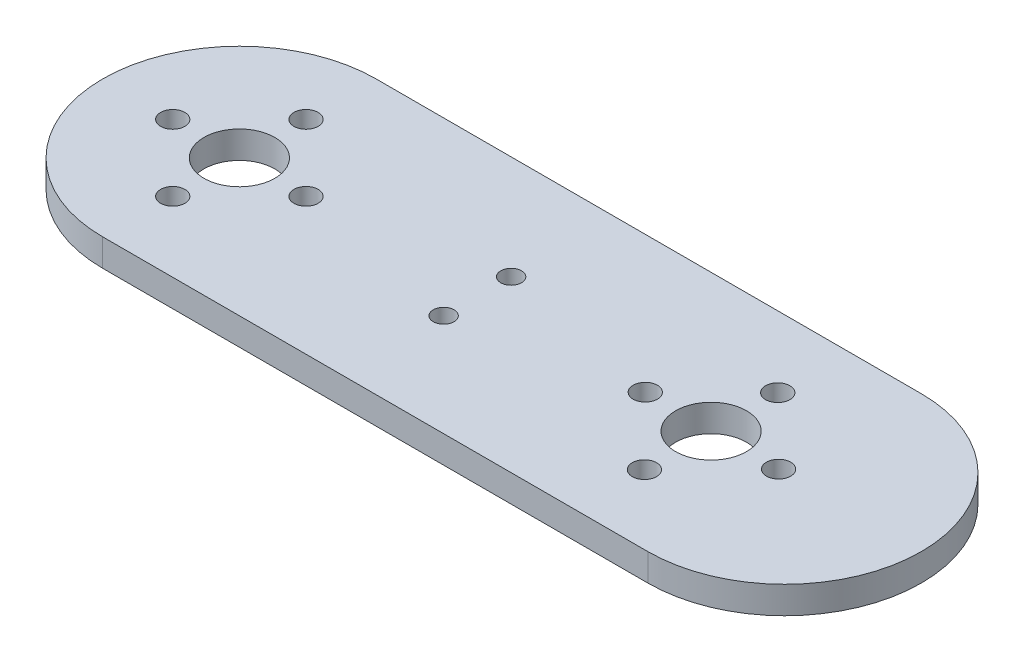
from build123d import *

# Parameters (mm, degrees)
SKETCH1_R               = 0.5
SKETCH1_R_2             = 1.375
BOSS_EXTRUDE1_DEPTH     = 2
SKETCH4_R               = 4.6270037
SKETCH4_R_2             = 2.6270037
BOSS_EXTRUDE3_DEPTH     = 2.5
CUT_EXTRUDE3_DEPTH      = 2.5
SKETCH6_R               = 20.066
SKETCH6_R_2             = 3.75
BOSS_EXTRUDE6_DEPTH     = 2.54
SKETCH7_R               = 1.778
CUT_EXTRUDE4_DEPTH      = 2.54
CIRPATTERN1_COUNT       = 4
BOSS_EXTRU_1_DEPTH      = 2.2225
BOSS_EXTRU_1_DEPTH_BACK = 2.54
ESQUISSE3_R             = 20.066
ESQUISSE3_R_2           = 1.778
ESQUISSE3_R_3           = 1.375
BOSS_EXTRU_2_DEPTH      = 2.2225
ENL_V_MAT_EXTRU_1_REACH = 104.179
ESQUISSE4_W             = 40.894
ESQUISSE4_H             = 20.066
ESQUISSE5_R             = 1.524
ENL_V_MAT_EXTRU_2_DEPTH = 103.178919246
ESQUISSE6_W             = 129.807809177
ESQUISSE6_H             = 84.506546368
ENL_V_MAT_EXTRU_3_DEPTH = 0.76
ESQUISSE7_R             = 5.2
ENL_V_MAT_EXTRU_4_DEPTH = 103.241877615
ESQUISSE8_W             = 40.894
ESQUISSE8_H             = 20.066
BOSS_EXTRU_3_DEPTH      = 4.0025
ESQUISSE9_R             = 5.2
ENL_V_MAT_EXTRU_5_DEPTH = 10
ESQUISSE11_R            = 1.78
ENL_V_MAT_EXTRU_6_DEPTH = 10
ESQUISSE10_R            = 1.524
BOSS_EXTRU_4_DEPTH      = 4.0025


with BuildPart() as part:
    # Sketch1 → Boss-Extrude1 (new body)
    with BuildSketch(Plane(origin=(0, 0, 0), x_dir=(1, 0, 0), z_dir=(0, 1, 0))):
        with BuildLine():
            Line((-4, 4), (-2.467435953, 13.402193757))
            ThreePointArc((-2.467435953, 13.402193757), (0, 15.5), (2.467435953, 13.402193757))
            Line((2.467435953, 13.402193757), (4, 4))
            Line((4, 4), (12.448472752, 2.459445505))
            ThreePointArc((12.448472752, 2.459445505), (14.5, 0), (12.448472752, -2.459445505))
            Line((12.448472752, -2.459445505), (4, -4))
            Line((4, -4), (2.467435953, -13.402193757))
            ThreePointArc((2.467435953, -13.402193757), (0, -15.5), (-2.467435953, -13.402193757))
            Line((-2.467435953, -13.402193757), (-4, -4))
            Line((-4, -4), (-12.448472752, -2.459445505))
            ThreePointArc((-12.448472752, -2.459445505), (-14.5, 0), (-12.448472752, 2.459445505))
            Line((-12.448472752, 2.459445505), (-4, 4))
        make_face()
        with Locations(Location((0, 12, 0), (0, 0, 270))):
            Circle(SKETCH1_R, mode=Mode.SUBTRACT)
        with Locations(Location((0, 9.5, 0), (0, 0, 270))):
            Circle(SKETCH1_R, mode=Mode.SUBTRACT)
        with Locations(Location((0, 7.5, 0), (0, 0, 270))):
            Circle(SKETCH1_R, mode=Mode.SUBTRACT)
        with Locations(Location((12, 0, 0), (0, 0, 270))):
            Circle(SKETCH1_R, mode=Mode.SUBTRACT)
        with Locations(Location((9.5, 0, 0), (0, 0, 270))):
            Circle(SKETCH1_R, mode=Mode.SUBTRACT)
        with Locations(Location((7.5, 0, 0), (0, 0, 270))):
            Circle(SKETCH1_R, mode=Mode.SUBTRACT)
        with Locations(Location((0, -12, 0), (0, 0, 270))):
            Circle(SKETCH1_R, mode=Mode.SUBTRACT)
        with Locations(Location((0, -9.5, 0), (0, 0, 270))):
            Circle(SKETCH1_R, mode=Mode.SUBTRACT)
        with Locations(Location((0, -7.5, 0), (0, 0, 270))):
            Circle(SKETCH1_R, mode=Mode.SUBTRACT)
        with Locations(Location((-12, 0, 0), (0, 0, 270))):
            Circle(SKETCH1_R, mode=Mode.SUBTRACT)
        with Locations(Location((-9.5, 0, 0), (0, 0, 270))):
            Circle(SKETCH1_R, mode=Mode.SUBTRACT)
        with Locations(Location((-7.5, 0, 0), (0, 0, 270))):
            Circle(SKETCH1_R, mode=Mode.SUBTRACT)
        with Locations(Location((0, 0, 0), (0, 0, 270))):
            Circle(SKETCH1_R_2, mode=Mode.SUBTRACT)
    extrude(amount=BOSS_EXTRUDE1_DEPTH)

    # Sketch4 → Boss-Extrude3 (add)
    with BuildSketch(Plane.XZ):
        with Locations(Location((0, 0, 0), (0, 0, 90))):
            Circle(SKETCH4_R)
        with Locations(Location((0, 0, 0), (0, 0, 270))):
            Circle(SKETCH4_R_2, mode=Mode.SUBTRACT)
    extrude(amount=BOSS_EXTRUDE3_DEPTH)

    # Sketch5 → Cut-Extrude3 (cut)
    with BuildSketch(Plane.XZ.offset(2.5)):
        with BuildLine():
            Line((0.282820055, 2.611735296), (0, 3.101594))
            Line((0, 3.101594), (-0.282820055, 2.611735296))
            ThreePointArc((-0.282820055, 2.611735296), (-0.410953918, 2.594660925), (-0.538092735, 2.571304075))
            Line((-0.538092735, 2.571304075), (-0.958445256, 2.949791185))
            Line((-0.958445256, 2.949791185), (-1.076048447, 2.396511669))
            ThreePointArc((-1.076048447, 2.396511669), (-1.192634723, 2.340677436), (-1.306333259, 2.279175696))
            Line((-1.306333259, 2.279175696), (-1.823071212, 2.509242256))
            Line((-1.823071212, 2.509242256), (-1.76394572, 1.946700782))
            ThreePointArc((-1.76394572, 1.946700782), (-1.85757213, 1.85757213), (-1.946700782, 1.76394572))
            Line((-1.946700782, 1.76394572), (-2.509242256, 1.823071212))
            Line((-2.509242256, 1.823071212), (-2.279175696, 1.306333259))
            ThreePointArc((-2.279175696, 1.306333259), (-2.340677436, 1.192634723), (-2.396511669, 1.076048447))
            Line((-2.396511669, 1.076048447), (-2.949791185, 0.958445256))
            Line((-2.949791185, 0.958445256), (-2.571304075, 0.538092735))
            ThreePointArc((-2.571304075, 0.538092735), (-2.594660925, 0.410953918), (-2.611735296, 0.282820055))
            Line((-2.611735296, 0.282820055), (-3.101594, 0))
            Line((-3.101594, 0), (-2.611735296, -0.282820055))
            ThreePointArc((-2.611735296, -0.282820055), (-2.594660925, -0.410953918), (-2.571304075, -0.538092735))
            Line((-2.571304075, -0.538092735), (-2.949791185, -0.958445256))
            Line((-2.949791185, -0.958445256), (-2.396511669, -1.076048447))
            ThreePointArc((-2.396511669, -1.076048447), (-2.340677436, -1.192634723), (-2.279175696, -1.306333259))
            Line((-2.279175696, -1.306333259), (-2.509242256, -1.823071212))
            Line((-2.509242256, -1.823071212), (-1.946700782, -1.76394572))
            ThreePointArc((-1.946700782, -1.76394572), (-1.85757213, -1.85757213), (-1.76394572, -1.946700782))
            Line((-1.76394572, -1.946700782), (-1.823071212, -2.509242256))
            Line((-1.823071212, -2.509242256), (-1.306333259, -2.279175696))
            ThreePointArc((-1.306333259, -2.279175696), (-1.192634723, -2.340677436), (-1.076048447, -2.396511669))
            Line((-1.076048447, -2.396511669), (-0.958445256, -2.949791185))
            Line((-0.958445256, -2.949791185), (-0.538092735, -2.571304075))
            ThreePointArc((-0.538092735, -2.571304075), (-0.410953918, -2.594660925), (-0.282820055, -2.611735296))
            Line((-0.282820055, -2.611735296), (0, -3.101594))
            Line((0, -3.101594), (0.282820055, -2.611735296))
            ThreePointArc((0.282820055, -2.611735296), (0.410953918, -2.594660925), (0.538092735, -2.571304075))
            Line((0.538092735, -2.571304075), (0.958445256, -2.949791185))
            Line((0.958445256, -2.949791185), (1.076048447, -2.396511669))
            ThreePointArc((1.076048447, -2.396511669), (1.192634723, -2.340677436), (1.306333259, -2.279175696))
            Line((1.306333259, -2.279175696), (1.823071212, -2.509242256))
            Line((1.823071212, -2.509242256), (1.76394572, -1.946700782))
            ThreePointArc((1.76394572, -1.946700782), (1.85757213, -1.85757213), (1.946700782, -1.76394572))
            Line((1.946700782, -1.76394572), (2.509242256, -1.823071212))
            Line((2.509242256, -1.823071212), (2.279175696, -1.306333259))
            ThreePointArc((2.279175696, -1.306333259), (2.340677436, -1.192634723), (2.396511669, -1.076048447))
            Line((2.396511669, -1.076048447), (2.949791185, -0.958445256))
            Line((2.949791185, -0.958445256), (2.571304075, -0.538092735))
            ThreePointArc((2.571304075, -0.538092735), (2.594660925, -0.410953918), (2.611735296, -0.282820055))
            Line((2.611735296, -0.282820055), (3.101594, 0))
            Line((3.101594, 0), (2.611735296, 0.282820055))
            ThreePointArc((2.611735296, 0.282820055), (2.594660925, 0.410953918), (2.571304075, 0.538092735))
            Line((2.571304075, 0.538092735), (2.949791185, 0.958445256))
            Line((2.949791185, 0.958445256), (2.396511669, 1.076048447))
            ThreePointArc((2.396511669, 1.076048447), (2.340677436, 1.192634723), (2.279175696, 1.306333259))
            Line((2.279175696, 1.306333259), (2.509242256, 1.823071212))
            Line((2.509242256, 1.823071212), (1.946700782, 1.76394572))
            ThreePointArc((1.946700782, 1.76394572), (1.85757213, 1.85757213), (1.76394572, 1.946700782))
            Line((1.76394572, 1.946700782), (1.823071212, 2.509242256))
            Line((1.823071212, 2.509242256), (1.306333259, 2.279175696))
            ThreePointArc((1.306333259, 2.279175696), (1.192634723, 2.340677436), (1.076048447, 2.396511669))
            Line((1.076048447, 2.396511669), (0.958445256, 2.949791185))
            Line((0.958445256, 2.949791185), (0.538092735, 2.571304075))
            ThreePointArc((0.538092735, 2.571304075), (0.410953918, 2.594660925), (0.282820055, 2.611735296))
        make_face()
    extrude(amount=-CUT_EXTRUDE3_DEPTH, mode=Mode.SUBTRACT)

    # Sketch6 → Boss-Extrude6 (add)
    with BuildSketch(Plane(origin=(0, 2, 0), x_dir=(1, 0, 0), z_dir=(0, 1, 0))):
        with Locations(Location((0, 0, 0), (0, 0, 270))):
            Circle(SKETCH6_R)
        Circle(SKETCH6_R_2, mode=Mode.SUBTRACT)
    extrude(amount=-BOSS_EXTRUDE6_DEPTH)

    # Sketch7 → Cut-Extrude4 (cut)
    with BuildSketch(Plane(origin=(0, 2, 0), x_dir=(1, 0, 0), z_dir=(0, 1, 0))):
        with Locations(Location((0, 9.779, 0), (0, 0, 270))):
            Circle(SKETCH7_R)
    cut_extrude4 = extrude(amount=-CUT_EXTRUDE4_DEPTH, mode=Mode.SUBTRACT)

    # CirPattern1: Cut-Extrude4 ×4 about axis
    cirpattern1_axis = Axis((0, 0, 0), (0, 1, 0))
    for i in range(1, CIRPATTERN1_COUNT):
        add(cut_extrude4.rotate(cirpattern1_axis, i * 360 / CIRPATTERN1_COUNT), mode=Mode.SUBTRACT)

    # Esquisse1 → Boss.-Extru.1 (add, two sides)
    with BuildSketch(Plane(origin=(0, 2, 0), x_dir=(1, 0, 0), z_dir=(0, 1, 0))) as boss_extru_1_sk:
        with BuildLine():
            Line((0, 20.066), (80.01, 20.066))
            ThreePointArc((80.01, 20.066), (100.076, 0), (80.01, -20.066))
            Line((80.01, -20.066), (0, -20.066))
            ThreePointArc((0, -20.066), (20.066, 0), (0, 20.066))
        make_face()
    extrude(amount=BOSS_EXTRU_1_DEPTH)
    extrude(boss_extru_1_sk.sketch, amount=-BOSS_EXTRU_1_DEPTH_BACK)

    # Esquisse3 → Boss.-Extru.2 (add)
    with BuildSketch(Plane(origin=(0, 2, 0), x_dir=(1, 0, 0), z_dir=(0, 1, 0))):
        Circle(ESQUISSE3_R)
        with Locations(Location((9.779, 0, 0), (0, 0, 270))):
            Circle(ESQUISSE3_R_2, mode=Mode.SUBTRACT)
        with Locations(Location((0, 9.779, 0), (0, 0, 270))):
            Circle(ESQUISSE3_R_2, mode=Mode.SUBTRACT)
        with Locations(Location((-9.779, 0, 0), (0, 0, 270))):
            Circle(ESQUISSE3_R_2, mode=Mode.SUBTRACT)
        with Locations(Location((0, -9.779, 0), (0, 0, 270))):
            Circle(ESQUISSE3_R_2, mode=Mode.SUBTRACT)
        with Locations(Location((0, 0, 0), (0, 0, 270))):
            Circle(ESQUISSE3_R_3, mode=Mode.SUBTRACT)
    extrude(amount=BOSS_EXTRU_2_DEPTH)

    # Esquisse4 → Enlèv. mat.-Extru.1 (cut, up to next)
    with BuildSketch(Plane.XZ.offset(0.54), mode=Mode.PRIVATE) as enl_v_mat_extru_1_sk1:
        with Locations((59.563, 0.127)):
            Rectangle(ESQUISSE4_W, ESQUISSE4_H)
    enl_v_mat_extru_1_tool1 = extrude(enl_v_mat_extru_1_sk1.sketch, amount=-ENL_V_MAT_EXTRU_1_REACH, mode=Mode.PRIVATE) & part.part
    add(enl_v_mat_extru_1_tool1.solids().sort_by_distance((59.563, -0.54, 0.127))[0], mode=Mode.SUBTRACT)

    # Esquisse5 → Enlèv. mat.-Extru.2 (cut, through all)
    with BuildSketch(Plane(origin=(0, -0.54, 0), x_dir=(-1, 0, 0), z_dir=(0, -1, 0))):
        with Locations(Location((-35.052, -5.08, 0), (0, 0, 90))):
            Circle(ESQUISSE5_R)
        with Locations(Location((-35.052, 4.826, 0), (0, 0, 90))):
            Circle(ESQUISSE5_R)
        with Locations(Location((-84.074, -5.08, 0), (0, 0, 90))):
            Circle(ESQUISSE5_R)
        with Locations(Location((-84.074, 4.826, 0), (0, 0, 90))):
            Circle(ESQUISSE5_R)
    extrude(amount=-ENL_V_MAT_EXTRU_2_DEPTH, mode=Mode.SUBTRACT)

    # Esquisse6 → Enlèv. mat.-Extru.3 (cut)
    with BuildSketch(Plane(origin=(0, 4.2225, 0), x_dir=(1, 0, 0), z_dir=(0, 1, 0))):
        with Locations((40.86254749, 2.128524174)):
            Rectangle(ESQUISSE6_W, ESQUISSE6_H)
    extrude(amount=-ENL_V_MAT_EXTRU_3_DEPTH, mode=Mode.SUBTRACT)

    # Esquisse7 → Enlèv. mat.-Extru.4 (cut, through all)
    with BuildSketch(Plane(origin=(0, -2.5, 0), x_dir=(-1, 0, 0), z_dir=(0, -1, 0))):
        with Locations(Location((0, 0, 0), (0, 0, 90))):
            Circle(ESQUISSE7_R)
    extrude(amount=-ENL_V_MAT_EXTRU_4_DEPTH, mode=Mode.SUBTRACT)

    # Esquisse8 → Boss.-Extru.3 (add, through all)
    with BuildSketch(Plane(origin=(0, -0.54, 0), x_dir=(-1, 0, 0), z_dir=(0, -1, 0))):
        with Locations((-59.563, -0.127)):
            Rectangle(ESQUISSE8_W, ESQUISSE8_H)
    extrude(amount=-BOSS_EXTRU_3_DEPTH)

    # Esquisse9 → Enlèv. mat.-Extru.5 (cut)
    with BuildSketch(Plane(origin=(0, -0.54, 0), x_dir=(-1, 0, 0), z_dir=(0, -1, 0))):
        with Locations(Location((-69.344, -0.125, 0), (0, 0, 90))):
            Circle(ESQUISSE9_R)
    extrude(amount=-ENL_V_MAT_EXTRU_5_DEPTH, mode=Mode.SUBTRACT)

    # Esquisse11 → Enlèv. mat.-Extru.6 (cut)
    with BuildSketch(Plane(origin=(0, 3.4625, 0), x_dir=(1, 0, 0), z_dir=(0, 1, 0))):
        with Locations(Location((69.344, 9.655, 0), (0, 0, 270))):
            Circle(ESQUISSE11_R)
        with Locations(Location((69.344, -9.905, 0), (0, 0, 270))):
            Circle(ESQUISSE11_R)
        with Locations(Location((59.564, 0, 0), (0, 0, 270))):
            Circle(ESQUISSE11_R)
        with Locations(Location((79.124, 0, 0), (0, 0, 270))):
            Circle(ESQUISSE11_R)
    extrude(amount=-ENL_V_MAT_EXTRU_6_DEPTH, mode=Mode.SUBTRACT)

    # Esquisse10 → Boss.-Extru.4 (add, through all)
    with BuildSketch(Plane(origin=(0, 3.4625, 0), x_dir=(1, 0, 0), z_dir=(0, 1, 0))):
        with Locations((84.074, 4.826)):
            Circle(ESQUISSE10_R)
        with Locations((84.074, -5.08)):
            Circle(ESQUISSE10_R)
    extrude(amount=-BOSS_EXTRU_4_DEPTH)


solid = part.part
